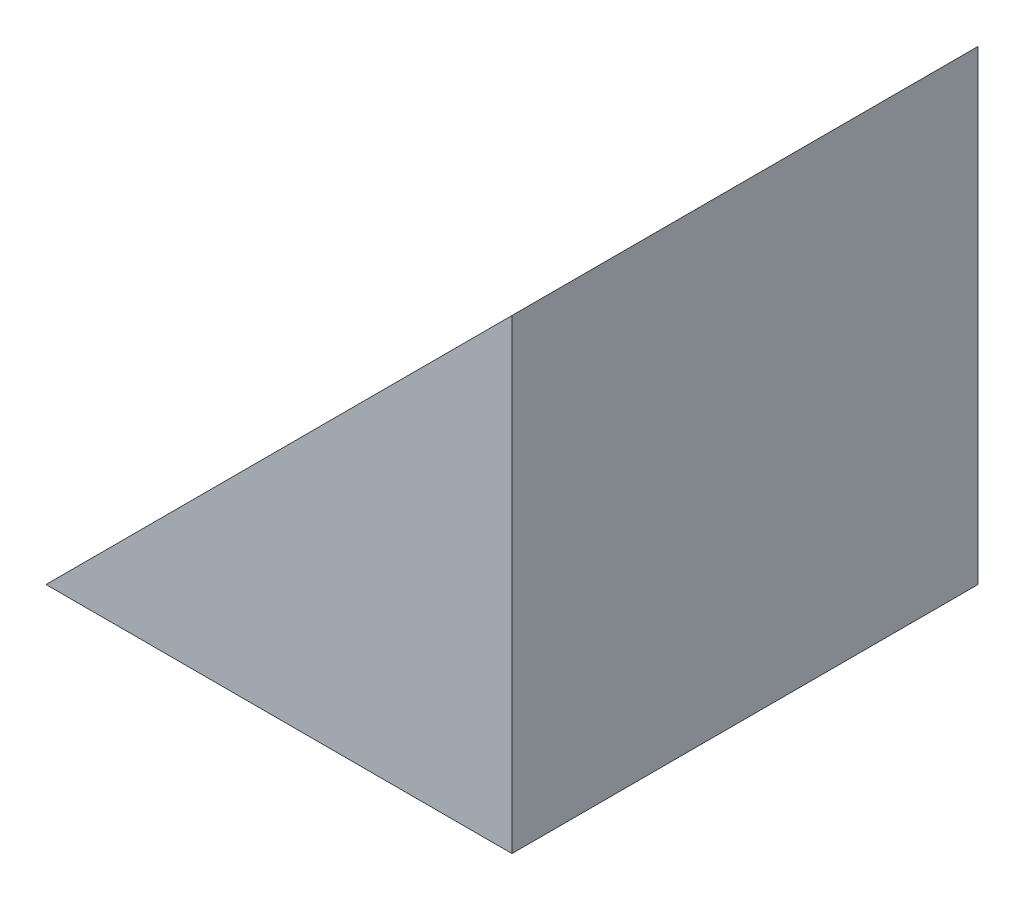
from build123d import *

# Parameters (mm, degrees)
EXTRUDE_1_DEPTH = 20


with BuildPart() as part:
    # 草图1 → 凸台-拉伸1 (new body)
    with BuildSketch(Plane.XY):
        Polygon((69.885625484, 53.111628096), (69.885625484, 73.111628096), (49.885625484, 53.111628096), align=None)
    extrude(amount=EXTRUDE_1_DEPTH)


solid = part.part
